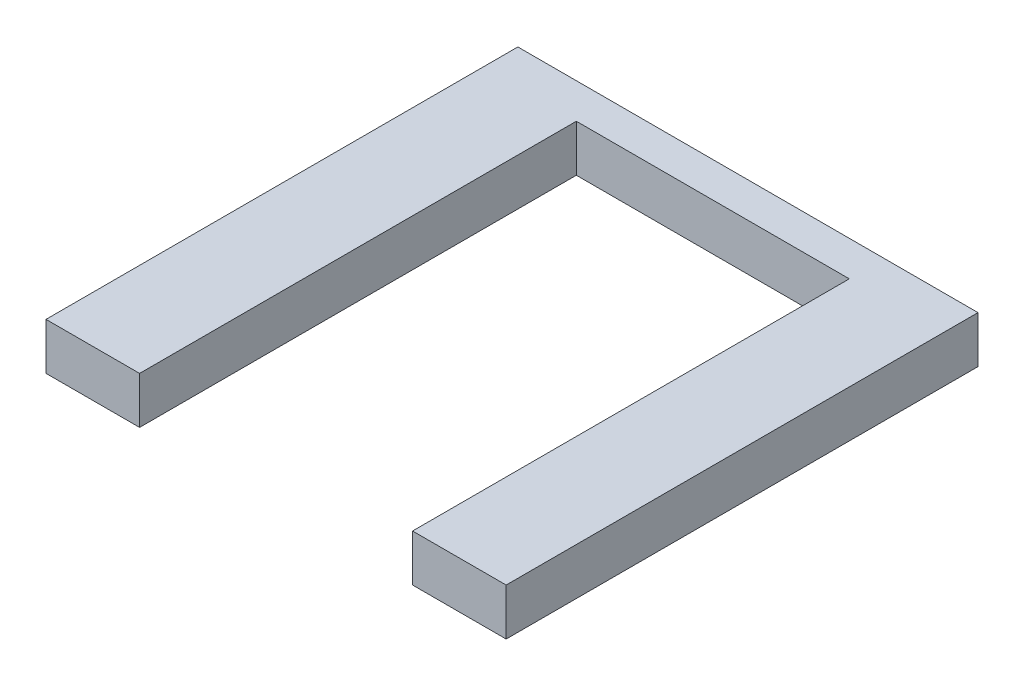
from build123d import *

# Parameters (mm, degrees)
SKETCH1_W           = 749.3
SKETCH1_H           = 768.35
BOSS_EXTRUDE1_DEPTH = 76.2
SKETCH2_W           = 444.5
SKETCH2_H           = 711.2
CUT_EXTRUDE1_DEPTH  = 76.2


with BuildPart() as part:
    # Sketch1 → Boss-Extrude1 (new body)
    with BuildSketch(Plane(origin=(0, 0, 0), x_dir=(1, 0, 0), z_dir=(0, 1, 0))):
        with Locations((374.65, -384.175)):
            Rectangle(SKETCH1_W, SKETCH1_H)
    extrude(amount=BOSS_EXTRUDE1_DEPTH)

    # Sketch2 → Cut-Extrude1 (cut)
    with BuildSketch(Plane(origin=(0, 76.2, 0), x_dir=(1, 0, 0), z_dir=(0, 1, 0))):
        with Locations((374.65, -412.75)):
            Rectangle(SKETCH2_W, SKETCH2_H)
    extrude(amount=-CUT_EXTRUDE1_DEPTH, mode=Mode.SUBTRACT)


solid = part.part
